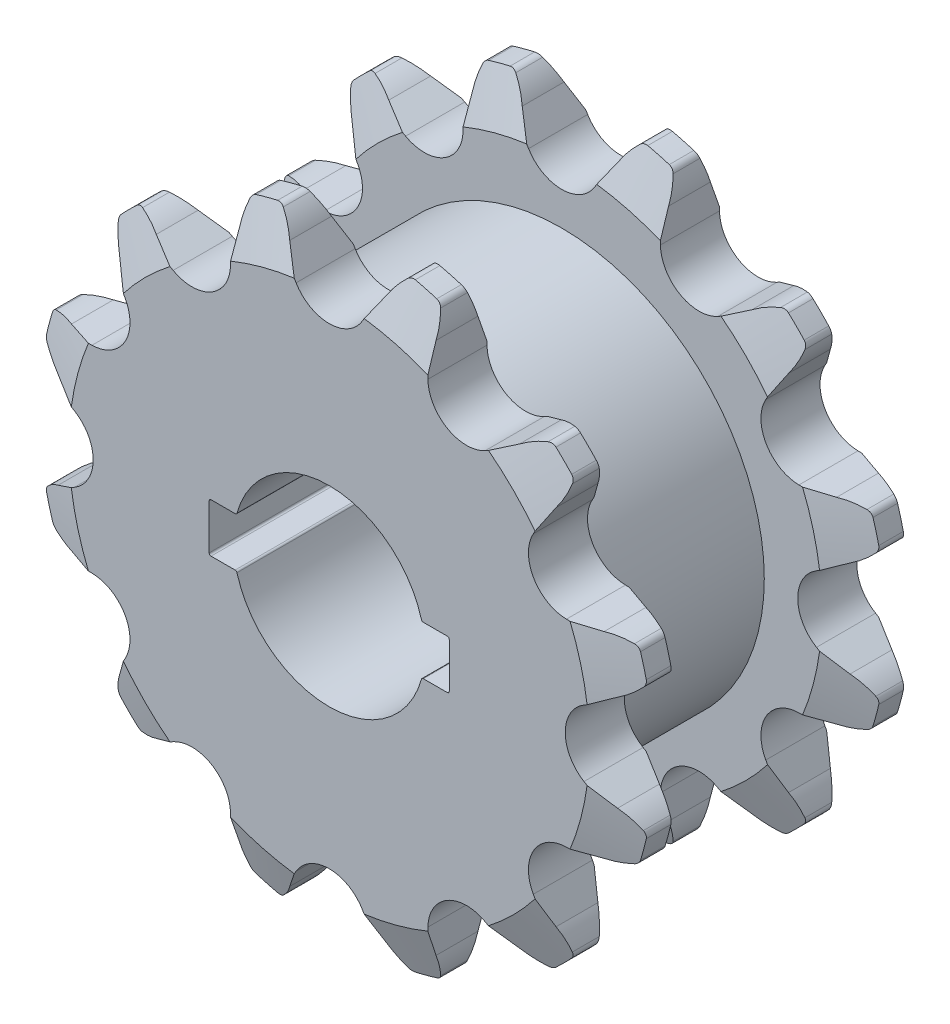
from build123d import *

# Parameters (mm, degrees)
SKETCH1_R             = 20.63242
EXTRUDE1_DEPTH        = 3.9624
SKETCH2_R             = 13.589
EXTRUDE2_DEPTH        = 11.6332
EXTRUDE3_DEPTH        = 19.558
CHAMFER1_SIZE         = 1.15824
CHAMFER1_SIZE2        = 3.175
CHAMFER1_PART_2_SIZE  = 1.15824
CHAMFER1_PART_2_SIZE2 = 3.175
CHAMFER2_SIZE         = 3.175
CHAMFER2_SIZE2        = 1.15824
CHAMFER2_PART_2_SIZE  = 3.175
CHAMFER2_PART_2_SIZE2 = 1.15824
CIRPATTERN1_COUNT     = 12
FILLET1_R             = 0.127
FILLET2_R             = 0.508


with BuildPart() as part:
    # Sketch1 → Extrude1 (new body)
    with BuildSketch(Plane.XY.offset(5.8166)):
        Circle(SKETCH1_R)
        with BuildLine():
            Line((6.213857059, 1.6383), (8.0518, 1.6383))
            Line((8.0518, 1.6383), (8.0518, -1.6383))
            Line((8.0518, -1.6383), (6.213857059, -1.6383))
            ThreePointArc((6.213857059, -1.6383), (0, -6.4262), (-6.213857059, -1.6383))
            Line((-6.213857059, -1.6383), (-8.0518, -1.6383))
            Line((-8.0518, -1.6383), (-8.0518, 1.6383))
            Line((-8.0518, 1.6383), (-6.213857059, 1.6383))
            ThreePointArc((-6.213857059, 1.6383), (0, 6.4262), (6.213857059, 1.6383))
        make_face(mode=Mode.SUBTRACT)
    extrude1 = extrude(amount=EXTRUDE1_DEPTH)

    # Sketch2 → Extrude2 (add)
    with BuildSketch(Plane(origin=(0, 0, 5.8166), x_dir=(-1, 0, 0), z_dir=(0, 0, -1))):
        Circle(SKETCH2_R)
        with BuildLine():
            Line((8.0518, 1.6383), (6.213857059, 1.6383))
            ThreePointArc((6.213857059, 1.6383), (0, 6.4262), (-6.213857059, 1.6383))
            Line((-6.213857059, 1.6383), (-8.0518, 1.6383))
            Line((-8.0518, 1.6383), (-8.0518, -1.6383))
            Line((-8.0518, -1.6383), (-6.213857059, -1.6383))
            ThreePointArc((-6.213857059, -1.6383), (0, -6.4262), (6.213857059, -1.6383))
            Line((6.213857059, -1.6383), (8.0518, -1.6383))
            Line((8.0518, -1.6383), (8.0518, 1.6383))
        make_face(mode=Mode.SUBTRACT)
    extrude(amount=EXTRUDE2_DEPTH)

    # Mirror5: Extrude1 across plane
    add(extrude1.mirror(Plane.XY))

    # Sketch3 → Extrude3 (cut)
    with BuildSketch(Plane.XY.offset(9.779)):
        with BuildLine():
            Line((2.2225, 17.091177778), (2.602762911, 17.725928806))
            Line((2.602762911, 17.725928806), (3.2258, 18.765928821))
            ThreePointArc((3.2258, 18.765928821), (3.722148235, 19.525786771), (4.366362838, 20.165109239))
            ThreePointArc((4.366362838, 20.165109239), (0, 20.63242), (-4.366362838, 20.165109239))
            ThreePointArc((-4.366362838, 20.165109239), (-3.722148235, 19.525786771), (-3.2258, 18.765928821))
            Line((-3.2258, 18.765928821), (-2.602762911, 17.725928806))
            Line((-2.602762911, 17.725928806), (-2.2225, 17.091177778))
            ThreePointArc((-2.2225, 17.091177778), (0, 15.83182), (2.2225, 17.091177778))
        make_face()
    extrude3 = extrude(amount=-EXTRUDE3_DEPTH, mode=Mode.SUBTRACT)

    # Chamfer1
    chamfer1_edges = [part.edges().sort_by_distance(p)[0] for p in [
        (0, -20.63242, 9.779),
    ]]
    chamfer1_side = [part.faces().sort_by_distance(p)[0] for p in [
        (0, -20.63242, 7.7978),
    ]]
    chamfer(chamfer1_edges, length=CHAMFER1_SIZE, length2=CHAMFER1_SIZE2, reference=chamfer1_side[0])

    # Chamfer1 part 2
    chamfer1_part_2_edges = [part.edges().sort_by_distance(p)[0] for p in [
        (0, -20.63242, -5.8166),
    ]]
    chamfer1_part_2_side = [part.faces().sort_by_distance(p)[0] for p in [
        (0, -20.63242, -7.7978),
    ]]
    chamfer(chamfer1_part_2_edges, length=CHAMFER1_PART_2_SIZE, length2=CHAMFER1_PART_2_SIZE2, reference=chamfer1_part_2_side[0])

    # Chamfer2
    chamfer2_edges = [part.edges().sort_by_distance(p)[0] for p in [
        (0, -20.63242, 5.8166),
    ]]
    chamfer2_side = [part.faces().sort_by_distance(p)[0] for p in [
        (0, -20.052142014, 5.8166),
    ]]
    chamfer(chamfer2_edges, length=CHAMFER2_SIZE, length2=CHAMFER2_SIZE2, reference=chamfer2_side[0])

    # Chamfer2 part 2
    chamfer2_part_2_edges = [part.edges().sort_by_distance(p)[0] for p in [
        (0, -20.63242, -9.779),
    ]]
    chamfer2_part_2_side = [part.faces().sort_by_distance(p)[0] for p in [
        (-4.171922903, 19.159146225, -9.779),
    ]]
    chamfer(chamfer2_part_2_edges, length=CHAMFER2_PART_2_SIZE, length2=CHAMFER2_PART_2_SIZE2, reference=chamfer2_part_2_side[0])

    # CirPattern1: Extrude3 ×12 about axis
    cirpattern1_axis = Axis((0, 0, 0), (0, 0, 1))
    for i in range(1, CIRPATTERN1_COUNT):
        add(extrude3.rotate(cirpattern1_axis, i * 360 / CIRPATTERN1_COUNT), mode=Mode.SUBTRACT)

    # Fillet1
    fillet1_edges = [part.edges().sort_by_distance(p)[0] for p in [
        (6.213857059, 1.6383, 0),
        (-6.213857059, 1.6383, 0),
        (-8.0518, 1.6383, 0),
        (-8.0518, -1.6383, 0),
        (-6.213857059, -1.6383, 0),
        (6.213857059, -1.6383, 0),
        (8.0518, -1.6383, 0),
        (8.0518, 1.6383, 0),
    ]]
    fillet(fillet1_edges, radius=FILLET1_R)

    # Fillet2
    fillet2_edges = [part.edges().sort_by_distance(p)[0] for p in [
        (-13.86393576, -15.280315452, -7.7978),
        (-15.280315452, -13.86393576, -7.7978),
        (-6.301173479, -19.64667829, 7.7978),
        (-4.366362838, -20.165109239, 7.7978),
        (-6.301173479, -19.64667829, -7.7978),
        (-4.366362838, -20.165109239, -7.7978),
        (4.366362838, -20.165109239, -7.7978),
        (6.301173479, -19.64667829, -7.7978),
        (4.366362838, -20.165109239, 7.7978),
        (6.301173479, -19.64667829, 7.7978),
        (13.86393576, -15.280315452, -7.7978),
        (15.280315452, -13.86393576, -7.7978),
        (13.86393576, -15.280315452, 7.7978),
        (15.280315452, -13.86393576, 7.7978),
        (19.64667829, -6.301173479, 7.7978),
        (20.165109239, -4.366362838, 7.7978),
        (19.64667829, -6.301173479, -7.7978),
        (20.165109239, -4.366362838, -7.7978),
        (20.165109239, 4.366362838, -7.7978),
        (19.64667829, 6.301173479, -7.7978),
        (15.280315452, 13.86393576, -7.7978),
        (13.86393576, 15.280315452, -7.7978),
        (20.165109239, 4.366362838, 7.7978),
        (19.64667829, 6.301173479, 7.7978),
        (15.280315452, 13.86393576, 7.7978),
        (13.86393576, 15.280315452, 7.7978),
        (6.301173479, 19.64667829, -7.7978),
        (4.366362838, 20.165109239, -7.7978),
        (-4.366362838, 20.165109239, -7.7978),
        (-6.301173479, 19.64667829, -7.7978),
        (6.301173479, 19.64667829, 7.7978),
        (4.366362838, 20.165109239, 7.7978),
        (-4.366362838, 20.165109239, 7.7978),
        (-6.301173479, 19.64667829, 7.7978),
        (-15.280315452, 13.86393576, 7.7978),
        (-13.86393576, 15.280315452, 7.7978),
        (-13.86393576, 15.280315452, -7.7978),
        (-15.280315452, 13.86393576, -7.7978),
        (-19.64667829, 6.301173479, -7.7978),
        (-20.165109239, 4.366362838, -7.7978),
        (-19.64667829, -6.301173479, -7.7978),
        (-20.165109239, -4.366362838, -7.7978),
        (-13.86393576, -15.280315452, 7.7978),
        (-15.280315452, -13.86393576, 7.7978),
        (-19.64667829, -6.301173479, 7.7978),
        (-20.165109239, -4.366362838, 7.7978),
        (-20.165109239, 4.366362838, 7.7978),
        (-19.64667829, 6.301173479, 7.7978),
    ]]
    fillet(fillet2_edges, radius=FILLET2_R)


solid = part.part
